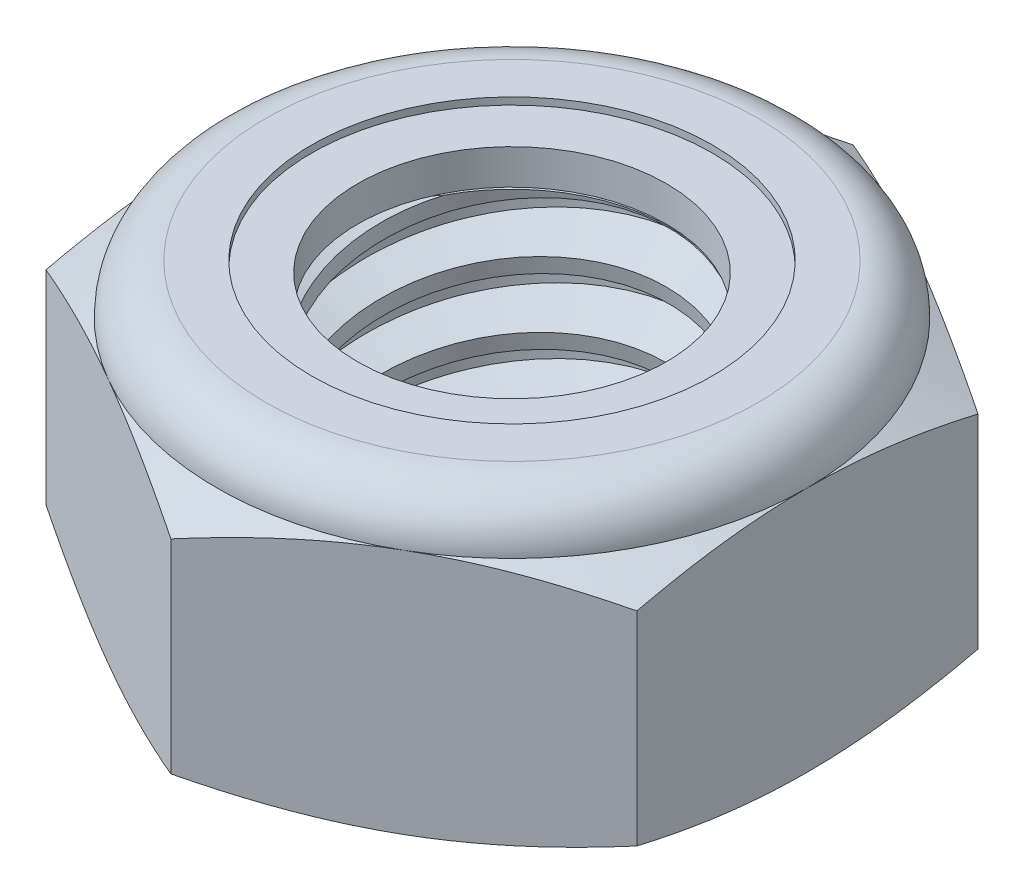
from build123d import *

# Parameters (mm, degrees)
EXTRUDE1_DEPTH       = 6.35
SKETCH2_W            = 3.9624
SKETCH2_H            = 6.35
LPATTERN1_COUNT      = 5
LPATTERN1_PITCH      = 1.411111111
LPATTERN1_COUNT_DIR2 = 2
LPATTERN1_PITCH_DIR2 = 1.411111111


with BuildPart() as part:
    # Sketch1 → Extrude1 (new body)
    with BuildSketch(Plane(origin=(0, 0, 0), x_dir=(1, 0, 0), z_dir=(0, 1, 0))):
        Polygon((0, 7.332348419), (-6.35, 3.666174209), (-6.35, -3.666174209), (0, -7.332348419), (6.35, -3.666174209), (6.35, 3.666174209), align=None)
    extrude(amount=EXTRUDE1_DEPTH)

    # Sketch4 → Cut-Revolve2 (revolve, cut)
    with BuildSketch(Plane(origin=(0, 0, 0), x_dir=(0, 0, -1), z_dir=(1, 0, 0))):
        Polygon((0, 6.35), (3.9624, 6.35), (3.318668226, 6.049822944), (3.318668226, 0.300177056), (3.9624, 0), (0, 0), align=None)
    revolve(axis=Axis((0, 6.35, 0), (0, 1, 0)), mode=Mode.SUBTRACT)


with BuildPart() as body_2:
    # Sketch2 → Revolve1 (revolve)
    with BuildSketch(Plane(origin=(0, 0, 0), x_dir=(0, 0, -1), z_dir=(1, 0, 0))):
        with Locations((1.9812, 3.175)):
            Rectangle(SKETCH2_W, SKETCH2_H)
    revolve(axis=Axis((0, -3.9624, 0), (0, 1, 0)))

    # Sketch3 → Cut-Revolve1 (revolve, cut)
    with BuildSketch(Plane(origin=(0, 0, 0), x_dir=(0, 0, -1), z_dir=(1, 0, 0))):
        Polygon((3.993321894, 6.176342646), (4.209775148, 4.960741167), (3.380512014, 5.260988826), (3.318668226, 5.608303534), align=None)
    cut_revolve1 = revolve(axis=Axis((0, 6.35, 0.26919352), (0, -0.9845141333311523, -0.17530522317150182)), mode=Mode.SUBTRACT)

    # LPattern1: Cut-Revolve1 5 × 2
    with Locations(*[Vector(0, -1, 0) * (i * LPATTERN1_PITCH) + Vector(0, 1, 0) * (j * LPATTERN1_PITCH_DIR2) for i in range(LPATTERN1_COUNT) for j in range(LPATTERN1_COUNT_DIR2) if (i, j) != (0, 0)]):
        add(cut_revolve1, mode=Mode.SUBTRACT)


with BuildPart() as part_1:
    add(part.part)

    # Combine1: cut body 2
    add(body_2.part, mode=Mode.SUBTRACT)

    # Sketch5 → Cut-Revolve3 (revolve, cut)
    with BuildSketch(Plane(origin=(0, 0, 0), x_dir=(0, 0, -1), z_dir=(1, 0, 0))):
        with BuildLine():
            Line((0, 0), (6.35, 0))
            Line((6.35, 0), (7.332348419, 0.458076591))
            Line((7.332348419, 0.458076591), (7.332348419, 4.833590076))
            Line((7.332348419, 4.833590076), (6.35, 5.291666667))
            ThreePointArc((6.35, 5.291666667), (6.040021343, 6.040021343), (5.291666667, 6.35))
            Line((5.291666667, 6.35), (5.291666667, 7.62))
            Line((5.291666667, 7.62), (8.602348419, 7.62))
            Line((8.602348419, 7.62), (8.602348419, -1.27))
            Line((8.602348419, -1.27), (0, -1.27))
            Line((0, -1.27), (0, 0))
        make_face()
    revolve(axis=Axis((0, 0, 0), (0, 1, 0)), mode=Mode.SUBTRACT)

    # Sketch6 → Cut-Revolve4 (revolve, cut)
    with BuildSketch(Plane(origin=(0, 0, 0), x_dir=(0, 0, -1), z_dir=(1, 0, 0))):
        with BuildLine():
            Line((0, 5.291666667), (6.1976, 5.291666667))
            ThreePointArc((6.1976, 5.291666667), (5.93225827, 5.93225827), (5.291666667, 6.1976))
            Line((5.291666667, 6.1976), (4.305167447, 6.1976))
            Line((4.305167447, 6.1976), (4.305167447, 7.62))
            Line((4.305167447, 7.62), (0, 7.62))
            Line((0, 7.62), (0, 5.291666667))
        make_face()
    revolve(axis=Axis((0, 7.62, 0), (0, 1, 0)), mode=Mode.SUBTRACT)


with BuildPart() as body_2_2:
    # Sketch7 → Revolve2 (revolve)
    with BuildSketch(Plane(origin=(0, 0, 0), x_dir=(0, 0, -1), z_dir=(1, 0, 0))):
        with BuildLine():
            Line((3.318668226, 5.367866667), (6.117893612, 5.367866667))
            ThreePointArc((6.117893612, 5.367866667), (5.850787282, 5.904725834), (5.291666667, 6.1214))
            Line((5.291666667, 6.1214), (3.318668226, 6.1214))
            Line((3.318668226, 6.1214), (3.318668226, 5.367866667))
        make_face()
    revolve(axis=Axis((0, 5.367866667, 0), (0, 1, 0)))


solid = Compound([part_1.part, body_2_2.part])
